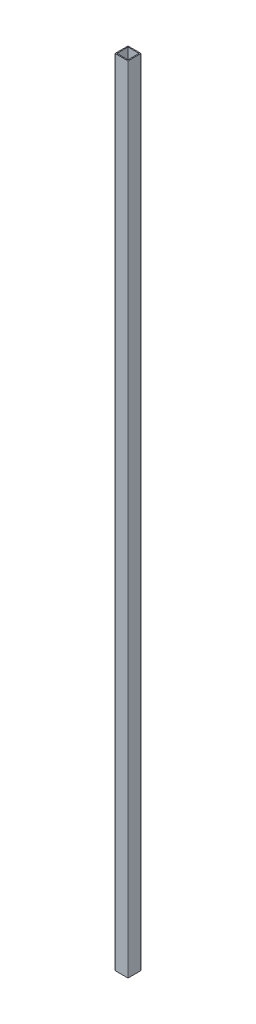
from build123d import *

# Parameters (mm, degrees)
SKETCH1_W           = 17
SKETCH1_H           = 17
BOSS_EXTRUDE1_DEPTH = 1220


with BuildPart() as part:
    # Sketch1 → Boss-Extrude1 (new body)
    with BuildSketch(Plane(origin=(0, 0, 0), x_dir=(1, 0, 0), z_dir=(0, 1, 0))):
        with BuildLine():
            Line((0.5, 0), (19.5, 0))
            ThreePointArc((19.5, 0), (19.853553391, 0.146446609), (20, 0.5))
            Line((20, 0.5), (20, 19.5))
            ThreePointArc((20, 19.5), (19.853553391, 19.853553391), (19.5, 20))
            Line((19.5, 20), (0.5, 20))
            ThreePointArc((0.5, 20), (0.146446609, 19.853553391), (0, 19.5))
            Line((0, 19.5), (0, 0.5))
            ThreePointArc((0, 0.5), (0.146446609, 0.146446609), (0.5, 0))
        make_face()
        with Locations((10, 10)):
            Rectangle(SKETCH1_W, SKETCH1_H, mode=Mode.SUBTRACT)
    extrude(amount=BOSS_EXTRUDE1_DEPTH)


solid = part.part
